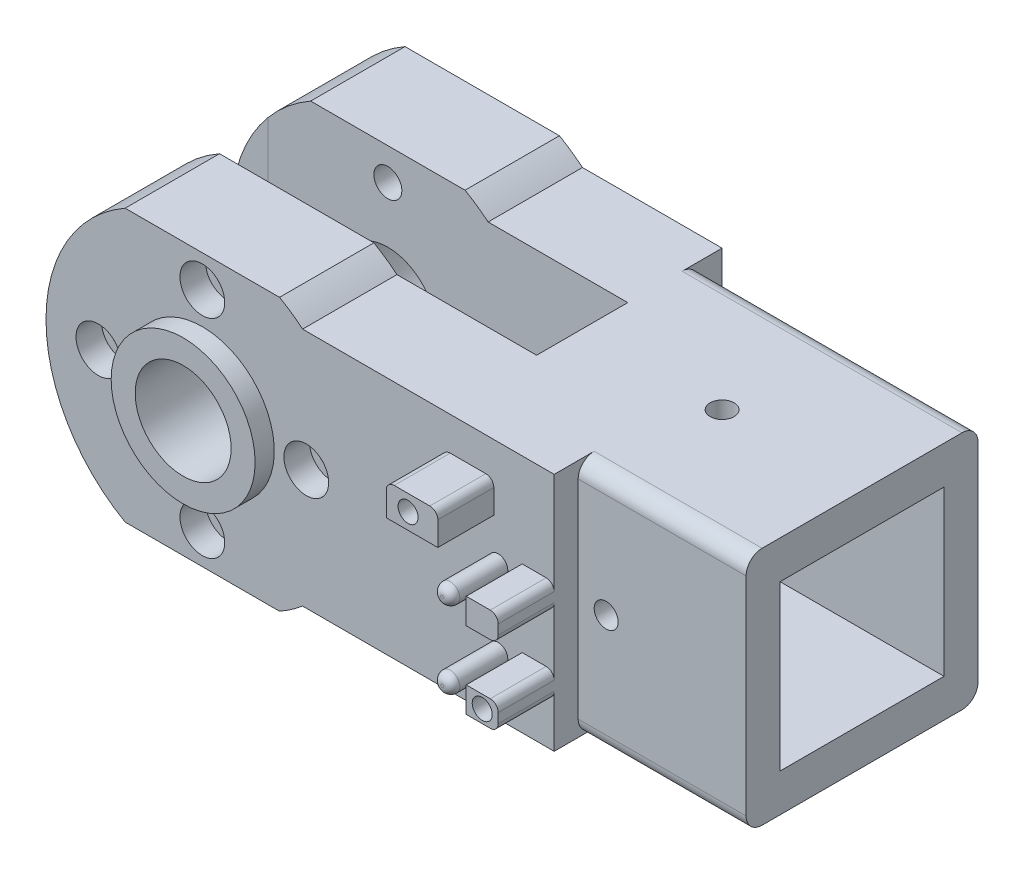
from build123d import *

# Parameters (mm, degrees)
ESTRUSIONE_ESTRUSIONE4_DEPTH       = 29
SCHIZZO12_W                        = 20.5
SCHIZZO12_H                        = 20.5
TAGLIO_ESTRUSIONE5_DEPTH           = 31
SCHIZZO13_R                        = 1.5
TAGLIO_ESTRUSIONE6_DEPTH           = 31
SCHIZZO14_R                        = 1.5
TAGLIO_ESTRUSIONE7_DEPTH           = 20
RACCORDO6_R                        = 2
SCHIZZO15_W                        = 11.8
SCHIZZO15_H                        = 30
ESTRUSIONE_ESTRUSIONE5_DEPTH       = 45
SCHIZZO16_R                        = 6
TAGLIO_ESTRUSIONE8_DEPTH           = 1
TAGLIO_ESTRUSIONE8_DEPTH_BACK      = 36
ESTRUSIONE_ESTRUSIONE7_DEPTH       = 11.8
ESTRUSIONE_ESTRUSIONE8_DEPTH       = 11.8
TAGLIO_ESTRUSIONE10_DEPTH          = 1
TAGLIO_ESTRUSIONE10_DEPTH_BACK     = 36
ESTRUSIONE_ESTRUSIONE9_DEPTH       = 11.8
ESTRUSIONE_ESTRUSIONE10_DEPTH      = 11.8
SCHIZZO23_R                        = 1.75
TAGLIO_ESTRUSIONE11_DEPTH          = 1
TAGLIO_ESTRUSIONE11_DEPTH_BACK     = 36
SCHIZZO24_R                        = 2.8
TAGLIO_ESTRUSIONE12_DEPTH          = 3.2
TAGLIO_ESTRUSIONE13_DEPTH          = 2.53
SCHIZZO31_R                        = 9
SCHIZZO31_R_2                      = 6
ESTRUSIONE_ESTRUSIONE16_DEPTH      = 2.4
SCHIZZO17_R                        = 1.2
SCHIZZO17_W                        = 4
SCHIZZO17_H                        = 3.2
SCHIZZO17_W_2                      = 6.451032108
SCHIZZO17_H_2                      = 4
ESTRUSIONE_ESTRUSIONE6_DEPTH       = 10
RACCORDO9_R                        = 1
SCHIZZO19_R                        = 1.25
TAGLIO_ESTRUSIONE9_DEPTH           = 8
SCHIZZO33_W                        = 14
SCHIZZO33_H                        = 30
ESTRUSIONE_ESTRUSIONE17_DEPTH      = 3
ESTRUSIONE_ESTRUSIONE17_DEPTH_BACK = 4.25


with BuildPart() as part:
    # Schizzo11 → Estrusione-Estrusione4 (new body)
    with BuildSketch(Plane.XY):
        Polygon((-14.5, 15), (14.5, 15), (14.5, -15), (-14.5, -15), (-20.5, -15), (-20.5, 15), align=None)
    extrude(amount=ESTRUSIONE_ESTRUSIONE4_DEPTH)

    # Schizzo12 → Taglio-Estrusione5 (cut)
    with BuildSketch(Plane(origin=(14.5, 0, 0), x_dir=(0, 0, -1), z_dir=(1, 0, 0))):
        with Locations((-14.5, 0)):
            Rectangle(SCHIZZO12_W, SCHIZZO12_H)
    extrude(amount=-TAGLIO_ESTRUSIONE5_DEPTH, mode=Mode.SUBTRACT)

    # Schizzo13 → Taglio-Estrusione6 (cut, through all)
    with BuildSketch(Plane.XZ.offset(15)):
        with Locations((-3, 14.5)):
            Circle(SCHIZZO13_R)
    extrude(amount=-TAGLIO_ESTRUSIONE6_DEPTH, mode=Mode.SUBTRACT)

    # Schizzo14 → Taglio-Estrusione7 (cut)
    with BuildSketch(Plane.XY.offset(29)):
        with Locations((-3, 0)):
            Circle(SCHIZZO14_R)
    extrude(amount=-TAGLIO_ESTRUSIONE7_DEPTH, mode=Mode.SUBTRACT)

    # Raccordo6
    raccordo6_edges = [part.edges().sort_by_distance(p)[0] for p in [
        (-3, 15, 29),
        (-3, -15, 29),
        (-3, -15, 0),
        (-3, 15, 0),
    ]]
    fillet(raccordo6_edges, radius=RACCORDO6_R)

    # Schizzo15 → Estrusione-Estrusione5 (add)
    with BuildSketch(Plane.ZY.offset(20.5)):
        with Locations((26.1, 0)):
            Rectangle(SCHIZZO15_W, SCHIZZO15_H)
        with Locations((2.9, 0)):
            Rectangle(SCHIZZO15_W, SCHIZZO15_H)
    extrude(amount=ESTRUSIONE_ESTRUSIONE5_DEPTH)

    # Schizzo16 → Taglio-Estrusione8 (cut, two sides)
    with BuildSketch(Plane.XY.offset(32)) as taglio_estrusione8_sk:
        with Locations((-50.5, 0)):
            Circle(SCHIZZO16_R)
    extrude(amount=TAGLIO_ESTRUSIONE8_DEPTH, mode=Mode.SUBTRACT)
    extrude(taglio_estrusione8_sk.sketch, amount=-TAGLIO_ESTRUSIONE8_DEPTH_BACK, mode=Mode.SUBTRACT)

    # Schizzo21 → Estrusione-Estrusione8 (add)
    with BuildSketch(Plane.XY.offset(32)):
        with BuildLine():
            Line((-65.5, -12.538042112), (-65.5, 12.538042112))
            ThreePointArc((-65.5, 12.538042112), (-70.05, 0), (-65.5, -12.538042112))
        make_face()
    extrude(amount=-ESTRUSIONE_ESTRUSIONE8_DEPTH)

    # Schizzo22 → Taglio-Estrusione10 (cut, two sides)
    with BuildSketch(Plane.XY.offset(32)) as taglio_estrusione10_sk:
        with BuildLine():
            ThreePointArc((-63.038042112, -15), (-64.323937572, -13.823937572), (-65.5, -12.538042112))
            Line((-65.5, -12.538042112), (-65.5, -15))
            Line((-65.5, -15), (-63.038042112, -15))
        make_face()
        with BuildLine():
            Line((-63.038042112, 15), (-65.5, 15))
            Line((-65.5, 15), (-65.5, 12.538042112))
            ThreePointArc((-65.5, 12.538042112), (-64.323937572, 13.823937572), (-63.038042112, 15))
        make_face()
    extrude(amount=TAGLIO_ESTRUSIONE10_DEPTH, mode=Mode.SUBTRACT)
    extrude(taglio_estrusione10_sk.sketch, amount=-TAGLIO_ESTRUSIONE10_DEPTH_BACK, mode=Mode.SUBTRACT)

    # Schizzo27 → Estrusione-Estrusione9 (add)
    with BuildSketch(Plane.XY.offset(32)):
        with BuildLine():
            ThreePointArc((-37.961957888, 15), (-39.358937071, 16.064844127), (-40.845855812, 17))
            Line((-40.845855812, 17), (-60.154144188, 17))
            ThreePointArc((-60.154144188, 17), (-61.641062929, 16.064844127), (-63.038042112, 15))
            Line((-63.038042112, 15), (-37.961957888, 15))
        make_face()
        with BuildLine():
            ThreePointArc((-40.845855812, -17), (-39.358937071, -16.064844127), (-37.961957888, -15))
            Line((-37.961957888, -15), (-63.038042112, -15))
            ThreePointArc((-63.038042112, -15), (-61.641062929, -16.064844127), (-60.154144188, -17))
            Line((-60.154144188, -17), (-40.845855812, -17))
        make_face()
    extrude(amount=-ESTRUSIONE_ESTRUSIONE9_DEPTH)

    # Schizzo29 → Estrusione-Estrusione10 (add)
    with BuildSketch(Plane(origin=(0, 0, -3), x_dir=(-1, 0, 0), z_dir=(0, 0, -1))):
        with BuildLine():
            Line((60.154144188, 17), (40.845855812, 17))
            ThreePointArc((40.845855812, 17), (39.358937071, 16.064844127), (37.961957888, 15))
            Line((37.961957888, 15), (63.038042112, 15))
            ThreePointArc((63.038042112, 15), (61.641062929, 16.064844127), (60.154144188, 17))
        make_face()
        with BuildLine():
            Line((63.038042112, -15), (37.961957888, -15))
            ThreePointArc((37.961957888, -15), (39.358937071, -16.064844127), (40.845855812, -17))
            Line((40.845855812, -17), (60.154144188, -17))
            ThreePointArc((60.154144188, -17), (61.641062929, -16.064844127), (63.038042112, -15))
        make_face()
    extrude(amount=-ESTRUSIONE_ESTRUSIONE10_DEPTH)

    # Schizzo23 → Taglio-Estrusione11 (cut, two sides)
    with BuildSketch(Plane.XY.offset(32)) as taglio_estrusione11_sk:
        with Locations((-63.5, 0)):
            Circle(SCHIZZO23_R)
        with Locations((-50.5, 13)):
            Circle(SCHIZZO23_R)
        with Locations((-50.5, -13)):
            Circle(SCHIZZO23_R)
        with Locations((-37.5, 0)):
            Circle(SCHIZZO23_R)
    extrude(amount=TAGLIO_ESTRUSIONE11_DEPTH, mode=Mode.SUBTRACT)
    extrude(taglio_estrusione11_sk.sketch, amount=-TAGLIO_ESTRUSIONE11_DEPTH_BACK, mode=Mode.SUBTRACT)

    # Schizzo24 → Taglio-Estrusione12 (cut)
    with BuildSketch(Plane.XY.offset(32)):
        with Locations((-63.5, 0)):
            Circle(SCHIZZO24_R)
        with Locations((-50.5, 13)):
            Circle(SCHIZZO24_R)
        with Locations((-37.5, 0)):
            Circle(SCHIZZO24_R)
        with Locations((-50.5, -13)):
            Circle(SCHIZZO24_R)
    extrude(amount=-TAGLIO_ESTRUSIONE12_DEPTH, mode=Mode.SUBTRACT)


with BuildPart() as body_2:
    # Schizzo20 → Estrusione-Estrusione7 (new body)
    with BuildSketch(Plane(origin=(0, 0, -3), x_dir=(-1, 0, 0), z_dir=(0, 0, -1))):
        with BuildLine():
            ThreePointArc((70.05, 0), (68.877329784, 6.669051657), (65.5, 12.538042112))
            Line((65.5, 12.538042112), (65.5, -12.538042112))
            ThreePointArc((65.5, -12.538042112), (68.877329784, -6.669051657), (70.05, 0))
        make_face()
    extrude(amount=-ESTRUSIONE_ESTRUSIONE7_DEPTH)


with BuildPart() as taglio_estrusione13_tool:
    # Schizzo25 → Taglio-Estrusione13 (new body)
    with BuildSketch(Plane(origin=(0, 0, -3), x_dir=(-1, 0, 0), z_dir=(0, 0, -1))):
        Polygon((63.5, 3.233161507), (60.7, 1.616580754), (60.7, -1.616580754), (63.5, -3.233161507), (66.3, -1.616580754), (66.3, 1.616580754), align=None)
        Polygon((50.5, 9.766838493), (53.3, 11.383419246), (53.3, 14.616580754), (50.5, 16.233161507), (47.7, 14.616580754), (47.7, 11.383419246), align=None)
        Polygon((37.5, -3.233161507), (40.3, -1.616580754), (40.3, 1.616580754), (37.5, 3.233161507), (34.7, 1.616580754), (34.7, -1.616580754), align=None)
        Polygon((50.5, -9.766838493), (47.7, -11.383419246), (47.7, -14.616580754), (50.5, -16.233161507), (53.3, -14.616580754), (53.3, -11.383419246), align=None)
    extrude(amount=-TAGLIO_ESTRUSIONE13_DEPTH)


with BuildPart() as part_1:
    add(part.part)

    # Taglio-Estrusione13: cut by taglio_estrusione13_tool
    add(taglio_estrusione13_tool.part, mode=Mode.SUBTRACT)

    # Schizzo31 → Estrusione-Estrusione16 (add)
    with BuildSketch(Plane.XY.offset(32)):
        with Locations((-50.5, 0)):
            Circle(SCHIZZO31_R)
        with Locations((-50.5, 0)):
            Circle(SCHIZZO31_R_2, mode=Mode.SUBTRACT)
    estrusione_estrusione16 = extrude(amount=ESTRUSIONE_ESTRUSIONE16_DEPTH)

    # Specchia3: Estrusione-Estrusione16 across plane
    add(estrusione_estrusione16.mirror(Plane.XY.offset(14.5)))

    # Schizzo17 → Estrusione-Estrusione6 (add)
    with BuildSketch(Plane.XY.offset(29)):
        with Locations((-13.5, 1.7)):
            Circle(SCHIZZO17_R)
        with Locations((-13.5, -7.9)):
            Circle(SCHIZZO17_R)
        with Locations((-8.5, -7.9)):
            Rectangle(SCHIZZO17_W, SCHIZZO17_H)
        with Locations((-8.5, 1.7)):
            Rectangle(SCHIZZO17_W, SCHIZZO17_H)
        with Locations((-17.274483946, 8.8)):
            Rectangle(SCHIZZO17_W_2, SCHIZZO17_H_2)
    extrude(amount=ESTRUSIONE_ESTRUSIONE6_DEPTH)

    # Raccordo9
    raccordo9_edges = [part_1.edges().sort_by_distance(p)[0] for p in [
        (-14.7, 1.7, 39),
        (-14.7, -7.9, 39),
        (-6.5, 0.1, 34),
        (-6.5, 3.3, 34),
        (-6.5, -9.5, 34),
        (-6.5, -6.3, 34),
        (-20.5, 10.8, 35.5),
        (-14.048967892, 10.8, 34),
    ]]
    fillet(raccordo9_edges, radius=RACCORDO9_R)

    # Schizzo19 → Taglio-Estrusione9 (cut)
    with BuildSketch(Plane.XY.offset(39)):
        with Locations((-8.5, -7.9)):
            Circle(SCHIZZO19_R)
        with Locations((-17.774483946, 8.8)):
            Circle(SCHIZZO19_R)
    extrude(amount=-TAGLIO_ESTRUSIONE9_DEPTH, mode=Mode.SUBTRACT)

    # Schizzo33 → Estrusione-Estrusione17 (add, two sides)
    with BuildSketch(Plane.XY.offset(29)) as estrusione_estrusione17_sk:
        with Locations((-13.5, 0)):
            Rectangle(SCHIZZO33_W, SCHIZZO33_H)
    extrude(amount=ESTRUSIONE_ESTRUSIONE17_DEPTH)
    extrude(estrusione_estrusione17_sk.sketch, amount=-ESTRUSIONE_ESTRUSIONE17_DEPTH_BACK)


with BuildPart() as body_2_1:
    add(body_2.part)

    # Taglio-Estrusione13: cut by taglio_estrusione13_tool
    add(taglio_estrusione13_tool.part, mode=Mode.SUBTRACT)


solid = Compound([part_1.part, body_2_1.part])
